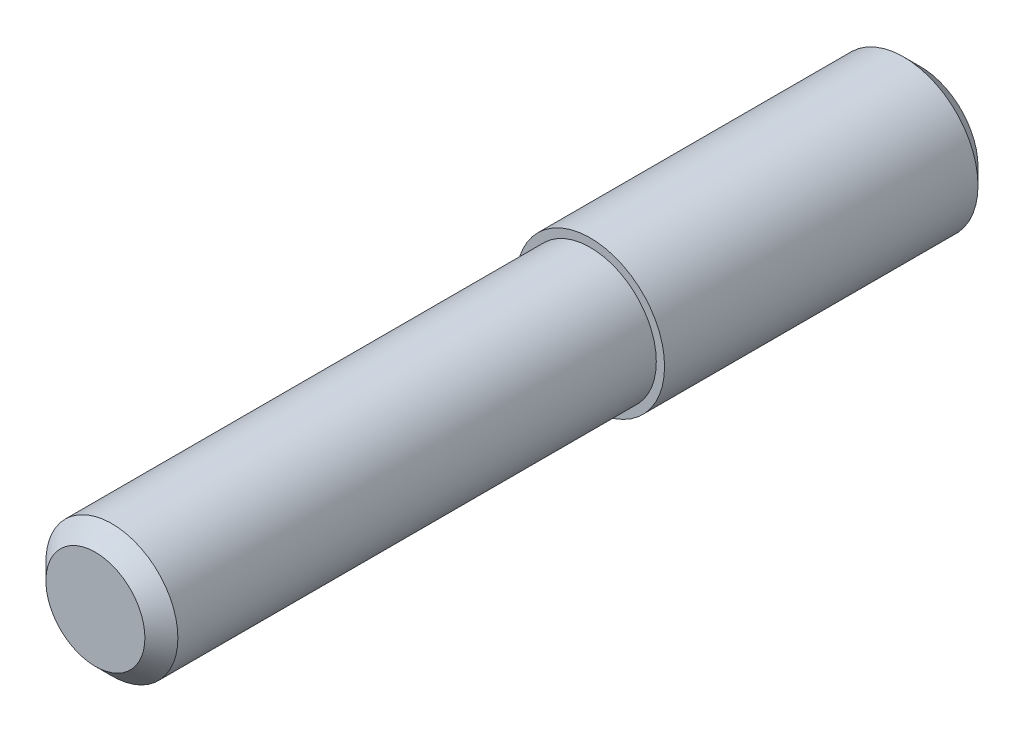
from build123d import *

# Parameters (mm, degrees)
ESQUISSE1_R        = 4.5
BOSS_EXTRU_2_DEPTH = 20
ESQUISSE2_R        = 4
BOSS_EXTRU_3_DEPTH = 30
CHANFREIN1_SIZE    = 1


with BuildPart() as part:
    # Esquisse1 → Boss.-Extru.2 (new body)
    with BuildSketch(Plane.XY):
        Circle(ESQUISSE1_R)
    extrude(amount=BOSS_EXTRU_2_DEPTH)

    # Esquisse2 → Boss.-Extru.3 (add)
    with BuildSketch(Plane.XY.offset(20)):
        Circle(ESQUISSE2_R)
    extrude(amount=BOSS_EXTRU_3_DEPTH)

    # Chanfrein1
    chanfrein1_edges = [part.edges().sort_by_distance(p)[0] for p in [
        (-4.5, 0, 0),
        (-4, 0, 50),
    ]]
    chamfer(chanfrein1_edges, length=CHANFREIN1_SIZE)


solid = part.part
